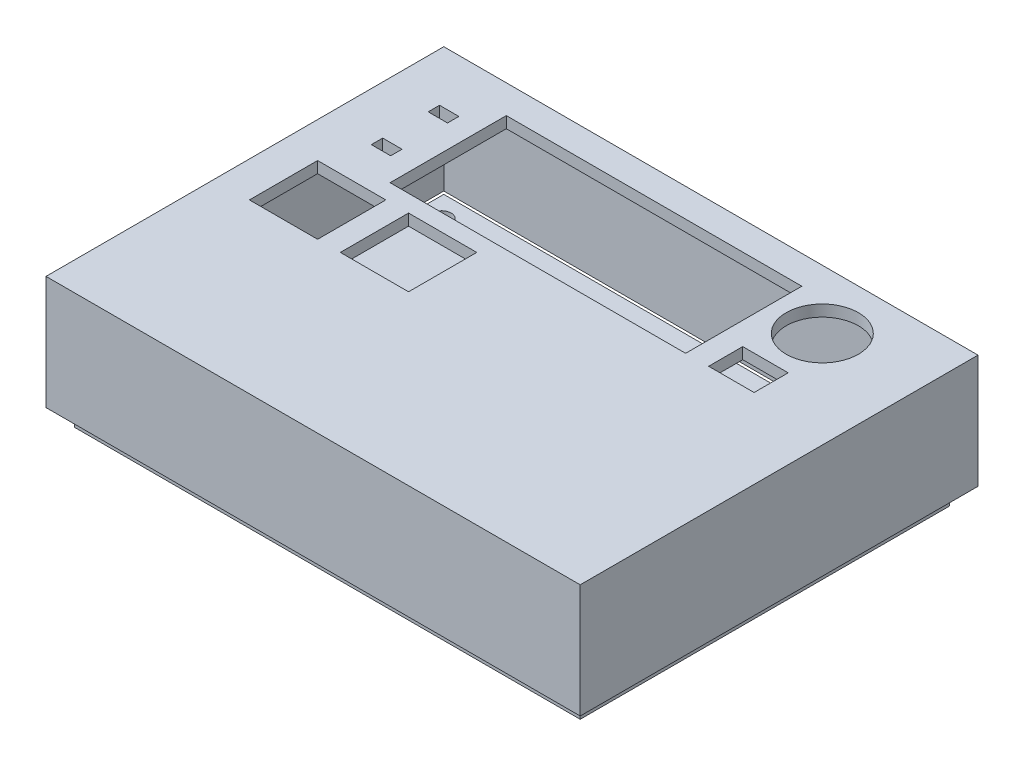
from build123d import *

# Parameters (mm, degrees)
SKETCH1_W                = 94
SKETCH1_H                = 70
SKETCH1_R                = 6.35
SKETCH1_W_2              = 8
SKETCH1_H_2              = 6
SKETCH1_W_3              = 3.4
SKETCH1_H_3              = 2
SKETCH1_W_4              = 52
SKETCH1_H_4              = 20.451642238
SKETCH1_W_5              = 12
SKETCH1_H_5              = 12
BOSS_EXTRUDE1_DEPTH      = 2
SKETCH2_W                = 94
SKETCH2_H                = 70
SKETCH2_W_2              = 90
SKETCH2_H_2              = 66
BOSS_EXTRUDE2_DEPTH      = 1
BOSS_EXTRUDE2_DEPTH_BACK = 18
CUT_EXTRUDE1_START       = -94
SKETCH3_W                = 7
SKETCH3_H                = 5.793277682
CUT_EXTRUDE1_DEPTH       = 10
CUT_EXTRUDE1_DEPTH_BACK  = 10
SKETCH4_W                = 89
SKETCH4_H                = 65
SKETCH4_W_2              = 7
SKETCH4_H_2              = 12
SKETCH4_W_3              = 6.5
SKETCH4_H_3              = 10
BOSS_EXTRUDE3_DEPTH      = 3
SKETCH5_R                = 1.7
CUT_EXTRUDE5_DEPTH       = 3


with BuildPart() as part:
    # Sketch1 → Boss-Extrude1 (new body)
    with BuildSketch(Plane(origin=(0, 0, 0), x_dir=(1, 0, 0), z_dir=(0, 1, 0))):
        with Locations((-6.75, 10.284411869)):
            Rectangle(SKETCH1_W, SKETCH1_H)
        with Locations((23.25, 34.886908177)):
            Circle(SKETCH1_R, mode=Mode.SUBTRACT)
        with Locations((22.25, 22.886908177)):
            Rectangle(SKETCH1_W_2, SKETCH1_H_2, mode=Mode.SUBTRACT)
        with Locations((-43.5, 24.984411869)):
            Rectangle(SKETCH1_W_3, SKETCH1_H_3, mode=Mode.SUBTRACT)
        with Locations((-11.75, 30.05859075)):
            Rectangle(SKETCH1_W_4, SKETCH1_H_4, mode=Mode.SUBTRACT)
        with Locations((-41.502745427, 10.832769631)):
            Rectangle(SKETCH1_W_5, SKETCH1_H_5, mode=Mode.SUBTRACT)
        with Locations((-25.502745427, 10.832769631)):
            Rectangle(SKETCH1_W_5, SKETCH1_H_5, mode=Mode.SUBTRACT)
        with Locations((-43.5, 34.984411869)):
            Rectangle(SKETCH1_W_3, SKETCH1_H_3, mode=Mode.SUBTRACT)
    extrude(amount=BOSS_EXTRUDE1_DEPTH)

    # Sketch2 → Boss-Extrude2 (add, two sides)
    with BuildSketch(Plane(origin=(0, 0, 0), x_dir=(1, 0, 0), z_dir=(0, 1, 0))) as boss_extrude2_sk:
        with Locations((-6.75, 10.284411869)):
            Rectangle(SKETCH2_W, SKETCH2_H)
        with Locations((-6.75, 10.284411869)):
            Rectangle(SKETCH2_W_2, SKETCH2_H_2, mode=Mode.SUBTRACT)
    extrude(amount=BOSS_EXTRUDE2_DEPTH)
    extrude(boss_extrude2_sk.sketch, amount=-BOSS_EXTRUDE2_DEPTH_BACK)

    # Sketch3 → Cut-Extrude1 (cut, two sides)
    with BuildSketch(Plane(origin=(40.25, 0, 0), x_dir=(0, 0, -1), z_dir=(1, 0, 0)).offset(CUT_EXTRUDE1_START)) as cut_extrude1_sk:
        with Locations((-10.515588131, -3.896638841)):
            Rectangle(SKETCH3_W, SKETCH3_H)
    extrude(amount=CUT_EXTRUDE1_DEPTH, mode=Mode.SUBTRACT)
    extrude(cut_extrude1_sk.sketch, amount=-CUT_EXTRUDE1_DEPTH_BACK, mode=Mode.SUBTRACT)


with BuildPart() as body_2:
    # Sketch4 → Boss-Extrude3 (new body)
    with BuildSketch(Plane.XZ.offset(18)):
        with Locations((-6.75, -10.284411869)):
            Rectangle(SKETCH4_W, SKETCH4_H)
        with Locations((-45.644363442, 14.215588131)):
            Rectangle(SKETCH4_W_2, SKETCH4_H_2, mode=Mode.SUBTRACT)
        with Locations((5.105636558, 16.215588131)):
            Rectangle(SKETCH4_W_3, SKETCH4_H_3, mode=Mode.SUBTRACT)
    extrude(amount=BOSS_EXTRUDE3_DEPTH)

    # Sketch5 → Cut-Extrude5 (cut)
    with BuildSketch(Plane(origin=(0, -21, 0), x_dir=(-1, 0, 0), z_dir=(0, -1, 0))):
        with Locations((-34.75, 39.784411869)):
            Circle(SKETCH5_R)
        with Locations((35.25, -15.115588131)):
            Circle(SKETCH5_R)
        with Locations((47.75, 38.884411869)):
            Circle(SKETCH5_R)
    extrude(amount=-CUT_EXTRUDE5_DEPTH, mode=Mode.SUBTRACT)


solid = Compound([part.part, body_2.part])
